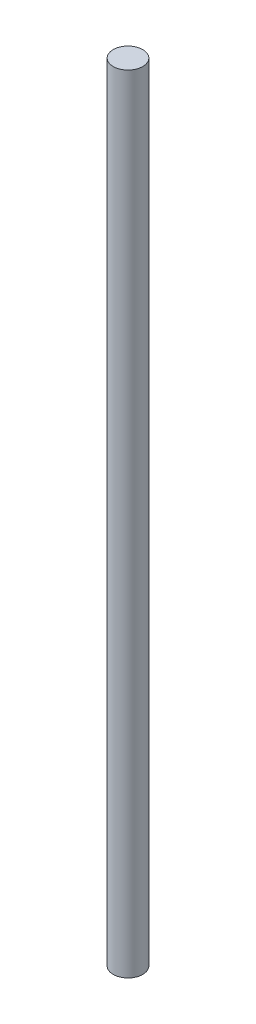
from build123d import *

# Parameters (mm, degrees)
SKETCH1_R           = 2.38125
BOSS_EXTRUDE1_DEPTH = 127


with BuildPart() as part:
    # Sketch1 → Boss-Extrude1 (new body)
    with BuildSketch(Plane(origin=(0, 0, 0), x_dir=(1, 0, 0), z_dir=(0, 1, 0))):
        Circle(SKETCH1_R)
    extrude(amount=BOSS_EXTRUDE1_DEPTH)


solid = part.part
